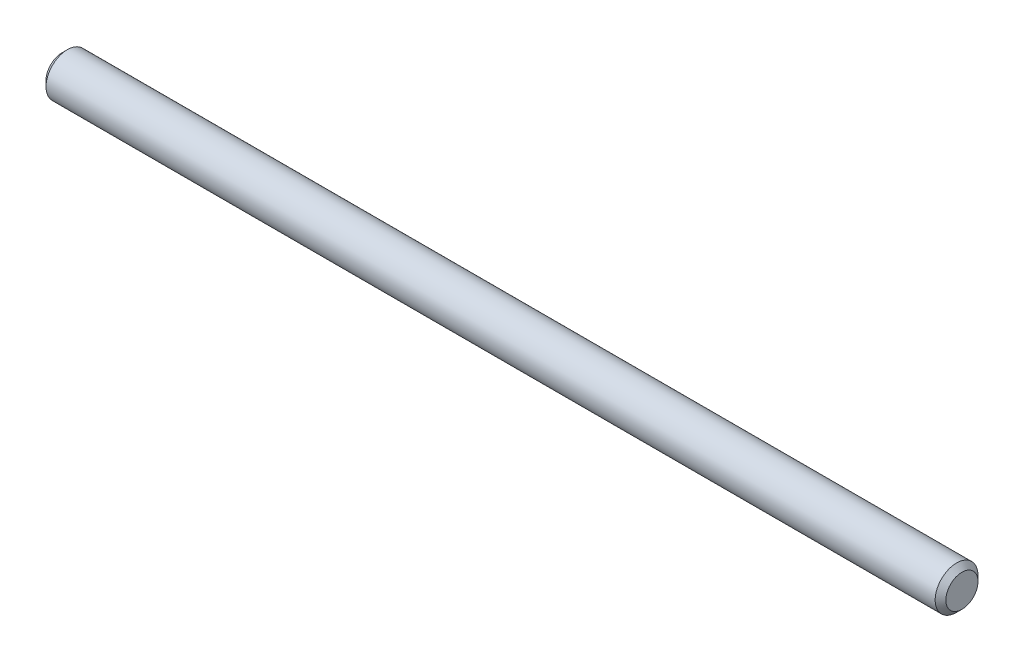
from build123d import *

# Parameters (mm, degrees)
SKETCH1_R           = 2
BOSS_EXTRUDE1_DEPTH = 84
CHAMFER1_SIZE       = 0.5
CHAMFER2_SIZE       = 0.5


with BuildPart() as part:
    # Sketch1 → Boss-Extrude1 (new body)
    with BuildSketch(Plane(origin=(0, 0, 0), x_dir=(0, 0, -1), z_dir=(1, 0, 0))):
        Circle(SKETCH1_R)
    extrude(amount=BOSS_EXTRUDE1_DEPTH)

    # Chamfer1
    chamfer1_edges = [part.edges().sort_by_distance(p)[0] for p in [
        (0, 0, 2),
    ]]
    chamfer(chamfer1_edges, length=CHAMFER1_SIZE)

    # Chamfer2
    chamfer2_edges = [part.edges().sort_by_distance(p)[0] for p in [
        (84, 0, 2),
    ]]
    chamfer(chamfer2_edges, length=CHAMFER2_SIZE)


solid = part.part
